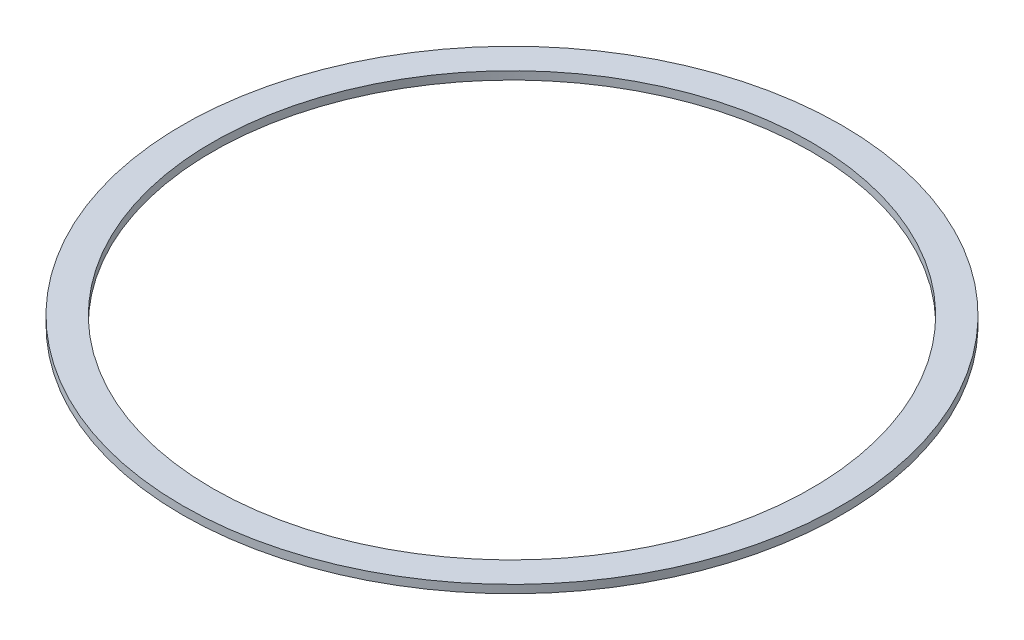
from build123d import *

# Parameters (mm, degrees)
SKETCH1_R           = 97.79
SKETCH1_R_2         = 88.9
BOSS_EXTRUDE1_DEPTH = 2.4


with BuildPart() as part:
    # Sketch1 → Boss-Extrude1 (new body)
    with BuildSketch(Plane(origin=(0, 0, 0), x_dir=(1, 0, 0), z_dir=(0, 1, 0))):
        Circle(SKETCH1_R)
        Circle(SKETCH1_R_2, mode=Mode.SUBTRACT)
    extrude(amount=BOSS_EXTRUDE1_DEPTH)


solid = part.part
